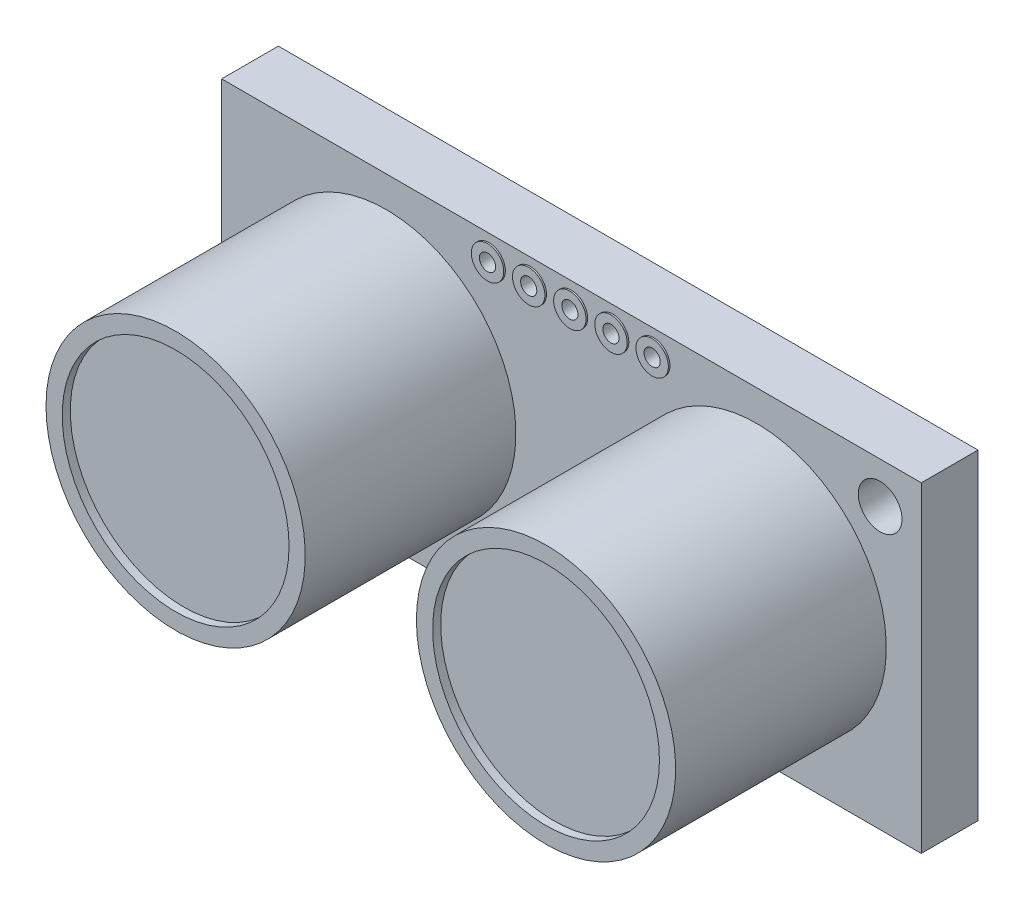
from build123d import *

# Parameters (mm, degrees)
SKETCH1_W                = 43.18
SKETCH1_H                = 19.812
SKETCH1_R                = 1.35
BOSS_EXTRUDE1_DEPTH      = 3.5
SKETCH2_R                = 8
BOSS_EXTRUDE2_DEPTH      = 13
SKETCH3_R                = 7
CUT_EXTRUDE1_DEPTH       = 0.5
SKETCH4_R                = 1
SKETCH4_R_2              = 0.5
EXTRUDE_THIN4_DEPTH      = 0.1
EXTRUDE_THIN4_DEPTH_BACK = 3.6
SKETCH11_R               = 0.5
CUT_EXTRUDE2_DEPTH       = 28.078717399
BOSS_EXTRUDE3_DEPTH      = 0.001


with BuildPart() as part:
    # Sketch1 → Boss-Extrude1 (new body)
    with BuildSketch(Plane.XY):
        Rectangle(SKETCH1_W, SKETCH1_H)
        with Locations((-19.05, -7.366)):
            Circle(SKETCH1_R, mode=Mode.SUBTRACT)
        with Locations((19.05, 7.366)):
            Circle(SKETCH1_R, mode=Mode.SUBTRACT)
    extrude(amount=BOSS_EXTRUDE1_DEPTH)

    # Sketch2 → Boss-Extrude2 (add)
    with BuildSketch(Plane.XY.offset(3.5)):
        with Locations(Location((-11.43, 0, 0), (0, 0, 180))):
            Circle(SKETCH2_R)
        with Locations(Location((11.43, 0, 0), (0, 0, 180))):
            Circle(SKETCH2_R)
    extrude(amount=BOSS_EXTRUDE2_DEPTH)

    # Sketch3 → Cut-Extrude1 (cut)
    with BuildSketch(Plane.XY.offset(16.5)):
        with Locations((-11.43, 0)):
            Circle(SKETCH3_R)
        with Locations((11.43, 0)):
            Circle(SKETCH3_R)
    extrude(amount=-CUT_EXTRUDE1_DEPTH, mode=Mode.SUBTRACT)

    # Sketch4 → Extrude-Thin4 (add, two sides)
    with BuildSketch(Plane.XY.offset(3.5)) as extrude_thin4_sk:
        with Locations((0, 8.406)):
            Circle(SKETCH4_R)
        with Locations((0, 8.406)):
            Circle(SKETCH4_R_2, mode=Mode.SUBTRACT)
        with Locations((2.54, 8.406)):
            Circle(SKETCH4_R)
        with Locations((2.54, 8.406)):
            Circle(SKETCH4_R_2, mode=Mode.SUBTRACT)
        with Locations((5.08, 8.406)):
            Circle(SKETCH4_R)
        with Locations((5.08, 8.406)):
            Circle(SKETCH4_R_2, mode=Mode.SUBTRACT)
        with Locations((-5.08, 8.406)):
            Circle(SKETCH4_R)
        with Locations((-5.08, 8.406)):
            Circle(SKETCH4_R_2, mode=Mode.SUBTRACT)
        with Locations((-2.54, 8.406)):
            Circle(SKETCH4_R)
        with Locations((-2.54, 8.406)):
            Circle(SKETCH4_R_2, mode=Mode.SUBTRACT)
        with Locations((-5.08, -8.406)):
            Circle(SKETCH4_R)
        with Locations((-5.08, -8.406)):
            Circle(SKETCH4_R_2, mode=Mode.SUBTRACT)
        with Locations((-2.54, -8.406)):
            Circle(SKETCH4_R)
        with Locations((-2.54, -8.406)):
            Circle(SKETCH4_R_2, mode=Mode.SUBTRACT)
        with Locations((0, -8.406)):
            Circle(SKETCH4_R)
        with Locations((0, -8.406)):
            Circle(SKETCH4_R_2, mode=Mode.SUBTRACT)
        with Locations((2.54, -8.406)):
            Circle(SKETCH4_R)
        with Locations((2.54, -8.406)):
            Circle(SKETCH4_R_2, mode=Mode.SUBTRACT)
        with Locations((5.08, -8.406)):
            Circle(SKETCH4_R)
        with Locations((5.08, -8.406)):
            Circle(SKETCH4_R_2, mode=Mode.SUBTRACT)
    extrude(amount=EXTRUDE_THIN4_DEPTH)
    extrude(extrude_thin4_sk.sketch, amount=-EXTRUDE_THIN4_DEPTH_BACK)

    # Sketch11 → Cut-Extrude2 (cut, through all)
    with BuildSketch(Plane.XY.offset(3.5)):
        with Locations((-5.08, -8.406)):
            Circle(SKETCH11_R)
        with Locations((-2.54, -8.406)):
            Circle(SKETCH11_R)
        with Locations(Location((0, -8.406, 0), (0, 0, 180))):
            Circle(SKETCH11_R)
        with Locations(Location((2.54, -8.406, 0), (0, 0, 180))):
            Circle(SKETCH11_R)
        with Locations(Location((5.08, -8.406, 0), (0, 0, 180))):
            Circle(SKETCH11_R)
        with Locations(Location((-5.08, 8.406, 0), (0, 0, 180))):
            Circle(SKETCH11_R)
        with Locations(Location((-2.54, 8.406, 0), (0, 0, 180))):
            Circle(SKETCH11_R)
        with Locations((0, 8.406)):
            Circle(SKETCH11_R)
        with Locations((2.54, 8.406)):
            Circle(SKETCH11_R)
        with Locations((5.08, 8.406)):
            Circle(SKETCH11_R)
    extrude(amount=-CUT_EXTRUDE2_DEPTH, mode=Mode.SUBTRACT)

    # Sketch12 → Boss-Extrude3 (add)
    with BuildSketch(Plane(origin=(0, 0, 0), x_dir=(-1, 0, 0), z_dir=(0, 0, -1))):
        with BuildLine():
            add(Edge.make_bspline(
                [(19.46929145, -2.683893026), (19.484417806, -2.684223579), (19.51433311, -2.684877312), (19.55857677, -2.689412347), (19.601609877, -2.696623598), (19.643529262, -2.706555749), (19.684115837, -2.719918963), (19.723610749, -2.736127809), (19.762201128, -2.75474264), (19.799136653, -2.77713075), (19.834715807, -2.80169308), (19.86828259, -2.829333068), (19.900019773, -2.859416979), (19.929842776, -2.892296508), (19.95696226, -2.928352739), (19.982882923, -2.966466663), (20.006501357, -3.007561369), (20.028166536, -3.051214815), (20.047339104, -3.097375117), (20.064173328, -3.145621658), (20.078768602, -3.195935133), (20.090261272, -3.24837133), (20.099075501, -3.302915202), (20.10540034, -3.359565322), (20.109601073, -3.418341945), (20.109976956, -3.458260498), (20.110167222, -3.478466619)],
                knots=[0, 0, 0, 0, 0.949010564, 1.876852617, 2.787529374, 3.685273709, 4.577074086, 5.465471387, 6.362587764, 7.262213343, 8.172580635, 9.073145362, 9.987411958, 10.914456489, 11.85451744, 12.815917507, 13.804911429, 14.825868585, 15.871774033, 16.938849417, 18.030625794, 19.156736427, 20.304747212, 21.4957645, 22.732396811, 24, 24, 24, 24], degree=3))
            add(Edge.make_bspline(
                [(20.110167222, -3.478466619), (20.109713592, -3.502551257), (20.108822914, -3.54984022), (20.103860332, -3.619166231), (20.094377913, -3.685161229), (20.082197449, -3.748129578), (20.065811319, -3.807833441), (20.045507132, -3.864154145), (20.022642346, -3.91766615), (20.003613894, -3.950828686), (19.994191581, -3.967249769)],
                knots=[0, 0, 0, 0, 1.136969792, 2.232382444, 3.278022597, 4.282276305, 5.258039159, 6.196692155, 7.1070566, 8, 8, 8, 8], degree=3))
            add(Edge.make_bspline(
                [(19.994191581, -3.967249769), (19.980125855, -3.988503916), (19.952188373, -4.030719109), (19.900998849, -4.087338382), (19.843562074, -4.138033515), (19.780391, -4.18158225), (19.714579966, -4.217072851), (19.648412339, -4.243220973), (19.582822371, -4.259318087), (19.539200268, -4.261525811), (19.517848725, -4.262606417)],
                knots=[0, 0, 0, 0, 1.048346287, 2.082235551, 3.132143771, 4.197203545, 5.234784445, 6.204564675, 7.121195205, 8, 8, 8, 8], degree=3))
            add(Edge.make_bspline(
                [(19.517848725, -4.262606417), (19.505880841, -4.261996217), (19.482506815, -4.260804457), (19.448934686, -4.251239838), (19.418256579, -4.235582628), (19.390595856, -4.214519543), (19.367774744, -4.188124339), (19.351003002, -4.157808329), (19.340409896, -4.124045436), (19.339393406, -4.100293963), (19.338869017, -4.088041007)],
                knots=[0, 0, 0, 0, 1.029346977, 2.010378973, 2.978887221, 3.98112847, 4.985683985, 5.960201932, 6.947705008, 8, 8, 8, 8], degree=3))
            add(Edge.make_bspline(
                [(19.338869017, -4.088041007), (19.339245694, -4.078080516), (19.339975706, -4.058776797), (19.348168728, -4.031204492), (19.36058334, -4.005800586), (19.37898544, -3.982970809), (19.401999508, -3.962194269), (19.429956992, -3.943235584), (19.462379414, -3.925486113), (19.486424996, -3.91601565), (19.498987635, -3.911067797)],
                knots=[0, 0, 0, 0, 0.932019786, 1.806281372, 2.676477655, 3.570524242, 4.53911087, 5.576821434, 6.734007876, 8, 8, 8, 8], degree=3))
            add(Edge.make_bspline(
                [(19.498987635, -3.911067797), (19.514154901, -3.904497014), (19.543429775, -3.891814514), (19.585067298, -3.871507385), (19.622251922, -3.849696316), (19.656489949, -3.82744116), (19.687800087, -3.802502501), (19.714997365, -3.772135305), (19.740183391, -3.737971347), (19.761936387, -3.698509866), (19.780332925, -3.653726361), (19.792758911, -3.602341133), (19.800986198, -3.544947653), (19.801631627, -3.504449709), (19.80196898, -3.483282216)],
                knots=[0, 0, 0, 0, 1.049630502, 2.025928848, 2.939419198, 3.785195675, 4.618337008, 5.47201057, 6.365697361, 7.308725407, 8.32613671, 9.430404736, 10.656922266, 12, 12, 12, 12], degree=3))
            add(Edge.make_bspline(
                [(19.80196898, -3.483282216), (19.801786665, -3.468289639), (19.801429478, -3.438916536), (19.797209523, -3.39604058), (19.790984576, -3.355224522), (19.781715623, -3.316744761), (19.770034495, -3.280393465), (19.756022784, -3.246070232), (19.739234454, -3.213860117), (19.719531242, -3.184397308), (19.698330902, -3.157558433), (19.676051651, -3.13356403), (19.651734729, -3.113808265), (19.626201925, -3.097691901), (19.599724219, -3.084476637), (19.571616619, -3.075919648), (19.542461561, -3.069773451), (19.522430697, -3.06935428), (19.512230528, -3.069140828)],
                knots=[0, 0, 0, 0, 1.280312405, 2.508357684, 3.676903495, 4.804965861, 5.885491899, 6.935930188, 7.96843881, 8.982636488, 9.958848435, 10.888398438, 11.773624114, 12.626391924, 13.464564268, 14.292153698, 15.130326042, 16, 16, 16, 16], degree=3))
            add(Edge.make_bspline(
                [(19.512230528, -3.069140828), (19.496494601, -3.069862799), (19.466161185, -3.071254509), (19.423077099, -3.083358943), (19.384333744, -3.102661617), (19.351407073, -3.130916015), (19.322475421, -3.164394049), (19.297717898, -3.203046341), (19.27585837, -3.245712555), (19.257854232, -3.293840184), (19.241563213, -3.348197534), (19.224705921, -3.410023046), (19.207664422, -3.480218562), (19.196344494, -3.529818585), (19.190388093, -3.555917479)],
                knots=[0, 0, 0, 0, 0.888922646, 1.713534847, 2.512522705, 3.3189352, 4.1507089, 5.009465297, 5.910012526, 6.858957344, 7.912524916, 9.120887575, 10.485048098, 12, 12, 12, 12], degree=3))
            add(Edge.make_bspline(
                [(19.190388093, -3.555917479), (19.181929691, -3.590087259), (19.165660619, -3.655810153), (19.138396278, -3.749704133), (19.107487465, -3.834351038), (19.075996763, -3.911613713), (19.039365433, -3.980627007), (18.996986053, -4.042080143), (18.948115752, -4.095761163), (18.902393794, -4.13442943), (18.86273622, -4.160699668), (18.831410889, -4.178047101), (18.798259358, -4.192636269), (18.763245036, -4.204110897), (18.726634467, -4.213350814), (18.688309172, -4.220246185), (18.648186982, -4.224299229), (18.620819207, -4.224686994), (18.606898192, -4.224884237)],
                knots=[0, 0, 0, 0, 1.736572963, 3.340162069, 4.820136415, 6.180570834, 7.453029487, 8.666721429, 9.853271306, 11.024342417, 11.610026699, 12.197789198, 12.78876586, 13.39394109, 14.013340947, 14.650211638, 15.313410593, 16, 16, 16, 16], degree=3))
            add(Edge.make_bspline(
                [(18.606898192, -4.224884237), (18.593504819, -4.224740931), (18.567042485, -4.224457791), (18.527951434, -4.219539845), (18.489840843, -4.213216925), (18.453112282, -4.202724962), (18.417329584, -4.190475928), (18.382581113, -4.175232627), (18.349418394, -4.156536443), (18.317126027, -4.135826985), (18.286692517, -4.111986582), (18.25762662, -4.08581059), (18.230312173, -4.057111963), (18.205669793, -4.025320842), (18.181514952, -3.992245277), (18.160416695, -3.955702998), (18.14091815, -3.91689848), (18.11625726, -3.861474515), (18.091695675, -3.786346212), (18.070365196, -3.689863343), (18.058072069, -3.585795903), (18.056383732, -3.513947159), (18.055512274, -3.47686142)],
                knots=[0, 0, 0, 0, 0.769461614, 1.520285473, 2.262551752, 2.988378485, 3.713226575, 4.436358852, 5.166208618, 5.900059362, 6.640050888, 7.38609301, 8.147789305, 8.914131076, 9.697346069, 10.500657756, 11.336485078, 12.193936862, 13.986438256, 15.869279717, 17.867870641, 20, 20, 20, 20], degree=3))
            add(Edge.make_bspline(
                [(18.055512274, -3.47686142), (18.05600825, -3.447276945), (18.056966469, -3.390120075), (18.065519679, -3.307472284), (18.079250927, -3.231021329), (18.098946205, -3.160799164), (18.123752788, -3.096740742), (18.151543955, -3.038011171), (18.183353447, -2.98499297), (18.218799743, -2.938098441), (18.256208591, -2.896738524), (18.29544728, -2.86187447), (18.334774717, -2.831879), (18.375544801, -2.808851006), (18.416194468, -2.790441669), (18.45663055, -2.777736893), (18.496605537, -2.769471846), (18.523121397, -2.768598858), (18.536269428, -2.768165983)],
                knots=[0, 0, 0, 0, 1.50180492, 2.901470176, 4.213680385, 5.441471803, 6.598163128, 7.697894763, 8.73692932, 9.731292389, 10.678417777, 11.563424905, 12.393422888, 13.184490135, 13.9355001, 14.655109254, 15.333128709, 16, 16, 16, 16], degree=3))
            add(Edge.make_bspline(
                [(18.536269428, -2.768165983), (18.547968876, -2.768793298), (18.571072832, -2.770032115), (18.604767094, -2.779696382), (18.636323295, -2.79565456), (18.665371842, -2.817096846), (18.690072435, -2.843185233), (18.708902898, -2.872979724), (18.719626181, -2.906578955), (18.72097737, -2.929949853), (18.721669933, -2.941928794)],
                knots=[0, 0, 0, 0, 0.996524447, 1.967926831, 2.962621832, 3.998325838, 5.031199617, 6.009342139, 6.979672482, 8, 8, 8, 8], degree=3))
            add(Edge.make_bspline(
                [(18.721669933, -2.941928794), (18.721237923, -2.952509599), (18.720422718, -2.97247568), (18.71565128, -3.000753797), (18.705808035, -3.024736317), (18.692326163, -3.045597334), (18.674096087, -3.06379414), (18.652013526, -3.082466258), (18.625325748, -3.101924205), (18.605379739, -3.114352949), (18.594859198, -3.120908502)],
                knots=[0, 0, 0, 0, 1.091037725, 2.058798536, 2.936702634, 3.743333543, 4.601209271, 5.578930148, 6.723004324, 8, 8, 8, 8], degree=3))
            add(Edge.make_bspline(
                [(18.594859198, -3.120908502), (18.575539247, -3.130312653), (18.538259559, -3.14845886), (18.487226134, -3.180663145), (18.443363111, -3.216252044), (18.411121732, -3.248091479), (18.388932809, -3.276172478), (18.375392396, -3.300675856), (18.36395225, -3.327916675), (18.354092471, -3.357915788), (18.347112663, -3.391039717), (18.341977684, -3.42710389), (18.338748427, -3.466102827), (18.338272979, -3.493040834), (18.338027329, -3.506958904)],
                knots=[0, 0, 0, 0, 1.547925219, 2.986869477, 4.337480217, 5.612327564, 6.244828973, 6.909713596, 7.622436063, 8.372459485, 9.181850378, 10.058552105, 10.996911345, 12, 12, 12, 12], degree=3))
            add(Edge.make_bspline(
                [(18.338027329, -3.506958904), (18.338865045, -3.532558407), (18.340463722, -3.581411873), (18.352743768, -3.651016511), (18.374037305, -3.712842943), (18.398984211, -3.758442548), (18.422788372, -3.789499691), (18.44081972, -3.810017039), (18.460169787, -3.826920103), (18.480431517, -3.840723538), (18.501450251, -3.851609225), (18.523287707, -3.860004514), (18.546272099, -3.86424575), (18.561805072, -3.864961487), (18.569577311, -3.865319621)],
                knots=[0, 0, 0, 0, 1.953936482, 3.728844638, 5.372901677, 6.927342473, 7.670868145, 8.357884895, 9.009286022, 9.626820382, 10.225224998, 10.813344112, 11.406232554, 12, 12, 12, 12], degree=3))
            add(Edge.make_bspline(
                [(18.569577311, -3.865319621), (18.579113211, -3.864980933), (18.597877953, -3.864314463), (18.624868169, -3.857681525), (18.649829947, -3.847135242), (18.67264924, -3.832338988), (18.693462973, -3.81368373), (18.712613766, -3.79174254), (18.73098022, -3.767342768), (18.751816257, -3.730051612), (18.774805884, -3.681539116), (18.791979424, -3.629173216), (18.805454941, -3.582429304), (18.816688397, -3.537433055), (18.831039039, -3.483002716), (18.840542262, -3.443308216), (18.845671569, -3.421883348)],
                knots=[0, 0, 0, 0, 0.710597064, 1.398312741, 2.060329599, 2.724976052, 3.418105476, 4.139422309, 4.896209246, 5.692466705, 7.322744487, 8.895039973, 9.798770174, 10.953818098, 12.355841563, 14, 14, 14, 14], degree=3))
            add(Edge.make_bspline(
                [(18.845671569, -3.421883348), (18.852243438, -3.39456596), (18.865099634, -3.341126413), (18.885959774, -3.263074468), (18.907992459, -3.189099277), (18.93074843, -3.118931762), (18.955043623, -3.053188778), (18.983131163, -2.992870483), (19.012545732, -2.937168657), (19.045060109, -2.886506913), (19.081514481, -2.841201333), (19.121641686, -2.800461623), (19.167070347, -2.766064391), (19.216582316, -2.736142614), (19.271527657, -2.71228591), (19.332434707, -2.695591819), (19.3989918, -2.685475813), (19.445309679, -2.684432972), (19.46929145, -2.683893026)],
                knots=[0, 0, 0, 0, 1.267425996, 2.479397737, 3.644026965, 4.748891262, 5.806868875, 6.803181051, 7.748078724, 8.646880768, 9.513885508, 10.367259778, 11.219353025, 12.077259478, 12.971817986, 13.911770136, 14.918787934, 16, 16, 16, 16], degree=3))
        make_face()
        with BuildLine():
            Line((19.236938869, -1.800230878), (19.236938869, -1.939080607))
            Line((19.236938869, -1.939080607), (19.867782146, -1.939080607))
            add(Edge.make_bspline(
                [(19.867782146, -1.939080607), (19.887227731, -1.939569463), (19.923611489, -1.940484139), (19.974280577, -1.950401281), (20.017014821, -1.967090735), (20.051586482, -1.990674356), (20.077777649, -2.01990028), (20.096740238, -2.053243428), (20.108349006, -2.090822708), (20.10955054, -2.117308302), (20.110167222, -2.130901909)],
                knots=[0, 0, 0, 0, 1.331902197, 2.492062242, 3.520752585, 4.456973203, 5.333663409, 6.188000262, 7.069999586, 8, 8, 8, 8], degree=3))
            add(Edge.make_bspline(
                [(20.110167222, -2.130901909), (20.109373291, -2.145409776), (20.107847372, -2.173293636), (20.09683532, -2.212967924), (20.076205729, -2.24664497), (20.048918398, -2.275511003), (20.013410064, -2.297766017), (19.970726045, -2.313122177), (19.921183627, -2.322818647), (19.88575683, -2.3238054), (19.866979546, -2.32432841)],
                knots=[0, 0, 0, 0, 0.98758274, 1.898116353, 2.767902367, 3.650180778, 4.579683533, 5.591031871, 6.723173417, 8, 8, 8, 8], degree=3))
            Line((19.866979546, -2.32432841), (18.351270222, -2.32432841))
            add(Edge.make_bspline(
                [(18.351270222, -2.32432841), (18.331280944, -2.323740288), (18.293773724, -2.322636755), (18.24188352, -2.311937018), (18.198309786, -2.294538775), (18.163257167, -2.268807182), (18.137095477, -2.234173002), (18.11923, -2.191152639), (18.108558909, -2.139709432), (18.107464294, -2.102600256), (18.106878648, -2.082745934)],
                knots=[0, 0, 0, 0, 1.204539147, 2.260157444, 3.178834964, 4.014831347, 4.849268471, 5.763683293, 6.803515522, 8, 8, 8, 8], degree=3))
            Line((18.106878648, -2.082745934), (18.106878648, -1.442271461))
            add(Edge.make_bspline(
                [(18.106878648, -1.442271461), (18.107059476, -1.42100132), (18.107407569, -1.380056515), (18.109303723, -1.320900151), (18.112849589, -1.266553391), (18.117921188, -1.216426566), (18.125407338, -1.169982505), (18.136034656, -1.126315058), (18.148886368, -1.084761869), (18.160527911, -1.058662721), (18.166271017, -1.045787265)],
                knots=[0, 0, 0, 0, 1.263018195, 2.431297115, 3.513891869, 4.496307935, 5.422122339, 6.30446181, 7.163542459, 8, 8, 8, 8], degree=3))
            add(Edge.make_bspline(
                [(18.166271017, -1.045787265), (18.173186513, -1.030381203), (18.186937288, -0.999747782), (18.213068639, -0.956540312), (18.243033035, -0.915964655), (18.27740064, -0.878682035), (18.314738259, -0.844403579), (18.35614933, -0.815189152), (18.399953527, -0.789676869), (18.44667819, -0.768825651), (18.495523638, -0.752581195), (18.54592107, -0.740211327), (18.597885926, -0.73347835), (18.632965113, -0.732475909), (18.650639869, -0.731970825)],
                knots=[0, 0, 0, 0, 0.991101386, 1.970706541, 2.959125982, 3.949043219, 4.94477413, 5.930285116, 6.919453739, 7.918248778, 8.929482208, 9.939493973, 10.961807665, 12, 12, 12, 12], degree=3))
            add(Edge.make_bspline(
                [(18.650639869, -0.731970825), (18.668583461, -0.73232809), (18.703639593, -0.733026073), (18.754754471, -0.73928432), (18.803248931, -0.748815301), (18.849139587, -0.762180424), (18.891914834, -0.780678697), (18.932132977, -0.802137642), (18.96957958, -0.827786237), (19.004173954, -0.857528021), (19.035791681, -0.89170093), (19.065916222, -0.928992469), (19.092585043, -0.97108369), (19.11714069, -1.016954235), (19.139142453, -1.067082964), (19.159163306, -1.121022773), (19.176521958, -1.179220962), (19.185676642, -1.219624181), (19.190388093, -1.240417665)],
                knots=[0, 0, 0, 0, 1.05507517, 2.061284822, 3.02416977, 3.960190338, 4.866266322, 5.760478336, 6.637811303, 7.530498893, 8.437803919, 9.372931164, 10.346335214, 11.363650695, 12.430976955, 13.56370004, 14.746160234, 16, 16, 16, 16], degree=3))
            add(Edge.make_bspline(
                [(19.190388093, -1.240417665), (19.200427827, -1.222376106), (19.220899361, -1.185588436), (19.259959389, -1.133796289), (19.304747277, -1.08278582), (19.356254388, -1.033986697), (19.411591028, -0.986799902), (19.469225772, -0.941636778), (19.528332151, -0.898760059), (19.588907267, -0.859624919), (19.648670628, -0.823618677), (19.706099342, -0.791258715), (19.760703138, -0.763640398), (19.811402894, -0.740153767), (19.856655487, -0.721449354), (19.894955835, -0.708122709), (19.925318671, -0.699169475), (19.94332506, -0.697397202), (19.950851203, -0.696656443)],
                knots=[0, 0, 0, 0, 1.035092047, 2.110606056, 3.247378518, 4.439119437, 5.667527541, 6.896357491, 8.113024158, 9.330801598, 10.514364801, 11.614385948, 12.638182879, 13.584379214, 14.418398752, 15.093545921, 15.621128711, 16, 16, 16, 16], degree=3))
            add(Edge.make_bspline(
                [(19.950851203, -0.696656443), (19.964041869, -0.697988111), (19.991453629, -0.700755473), (20.022873295, -0.717654824), (20.046183068, -0.73517527), (20.062660295, -0.75101425), (20.076500599, -0.769624107), (20.088663848, -0.79012526), (20.098335005, -0.812632242), (20.105021051, -0.837084422), (20.109741287, -0.863148392), (20.110023058, -0.881232034), (20.110167222, -0.890484244)],
                knots=[0, 0, 0, 0, 1.421053962, 2.95311776, 3.768369014, 4.575895034, 5.411397774, 6.266672613, 7.147343469, 8.048766422, 9.001682164, 10, 10, 10, 10], degree=3))
            add(Edge.make_bspline(
                [(20.110167222, -0.890484244), (20.109832205, -0.901356962), (20.109185491, -0.922345541), (20.10279153, -0.952381058), (20.093565654, -0.980199809), (20.074127778, -1.012575278), (20.044129385, -1.049196215), (20.006138096, -1.079661725), (19.970415066, -1.103157313), (19.937742869, -1.124120877), (19.899373952, -1.148105272), (19.871683967, -1.164876217), (19.856947051, -1.173801899)],
                knots=[0, 0, 0, 0, 0.812054064, 1.56758039, 2.289145878, 2.992867892, 4.379130512, 5.807652158, 6.615255223, 7.578411575, 8.711203985, 10, 10, 10, 10], degree=3))
            Line((19.856947051, -1.173801899), (19.591687887, -1.335124416))
            add(Edge.make_bspline(
                [(19.591687887, -1.335124416), (19.568712309, -1.348871396), (19.525264039, -1.374867804), (19.465196917, -1.414237897), (19.413821081, -1.45135698), (19.370496318, -1.486425891), (19.334807335, -1.520807514), (19.305094614, -1.55469524), (19.282105713, -1.589560527), (19.264098857, -1.62500043), (19.25142667, -1.663012017), (19.243523551, -1.704868082), (19.237482435, -1.750965884), (19.237125087, -1.783353374), (19.236938869, -1.800230878)],
                knots=[0, 0, 0, 0, 1.549240544, 2.929711722, 4.154429701, 5.215920692, 6.152032193, 7.019334908, 7.817977517, 8.562251951, 9.313736963, 10.127430344, 11.024181782, 12, 12, 12, 12], degree=3))
        make_face()
        with BuildLine():
            Line((18.41507689, -1.573095194), (18.41507689, -1.939080607))
            Line((18.41507689, -1.939080607), (18.954423814, -1.939080607))
            Line((18.954423814, -1.939080607), (18.954423814, -1.583930289))
            add(Edge.make_bspline(
                [(18.954423814, -1.583930289), (18.954079771, -1.561052235), (18.95341716, -1.516990022), (18.949415073, -1.453810733), (18.941134359, -1.396364754), (18.930772368, -1.34454499), (18.916521718, -1.298160403), (18.897635038, -1.257536318), (18.874321584, -1.222486007), (18.846171277, -1.193339399), (18.812927068, -1.170191533), (18.773918643, -1.154204272), (18.729500531, -1.144486988), (18.698046819, -1.143447393), (18.681539953, -1.142901815)],
                knots=[0, 0, 0, 0, 1.392674693, 2.682235545, 3.849820756, 4.922907172, 5.896284646, 6.795937237, 7.640517491, 8.44662346, 9.24840026, 10.087665541, 10.996409465, 12, 12, 12, 12], degree=3))
            add(Edge.make_bspline(
                [(18.681539953, -1.142901815), (18.668249815, -1.143268512), (18.642212955, -1.143986913), (18.604681271, -1.152433954), (18.569452481, -1.16532031), (18.537115649, -1.183502086), (18.507412206, -1.205750853), (18.482699331, -1.233431705), (18.460183411, -1.263853075), (18.44971231, -1.287133705), (18.444371775, -1.299007435)],
                knots=[0, 0, 0, 0, 1.054707271, 2.066288818, 3.042079463, 4.027441999, 5.005836686, 5.976573042, 6.967999406, 8, 8, 8, 8], degree=3))
            add(Edge.make_bspline(
                [(18.444371775, -1.299007435), (18.441988909, -1.305526806), (18.436809149, -1.319698305), (18.430881077, -1.343610178), (18.426457055, -1.371717154), (18.421820998, -1.403777985), (18.418718916, -1.440083634), (18.417027438, -1.480653587), (18.415124285, -1.525457961), (18.415093129, -1.556773176), (18.41507689, -1.573095194)],
                knots=[0, 0, 0, 0, 0.601274756, 1.307022564, 2.130372336, 3.066540635, 4.11402688, 5.286356465, 6.585603249, 8, 8, 8, 8], degree=3))
        make_face(mode=Mode.SUBTRACT)
        with BuildLine():
            Line((18.41507689, 0.831091874), (18.41507689, 0.03852478))
            Line((18.41507689, 0.03852478), (18.90305744, 0.03852478))
            Line((18.90305744, 0.03852478), (18.90305744, 0.701070741))
            add(Edge.make_bspline(
                [(18.90305744, 0.701070741), (18.903613439, 0.715413667), (18.904661621, 0.742453239), (18.911903609, 0.780369065), (18.925277155, 0.812518682), (18.943900572, 0.838849766), (18.967510759, 0.858807873), (18.994304088, 0.873595087), (19.02506835, 0.882258308), (19.04666647, 0.883180155), (19.057959161, 0.883662148)],
                knots=[0, 0, 0, 0, 1.26669481, 2.387998457, 3.388485007, 4.319542635, 5.207485584, 6.095585677, 7.004267047, 8, 8, 8, 8], degree=3))
            add(Edge.make_bspline(
                [(19.057959161, 0.883662148), (19.069130511, 0.88321293), (19.090655946, 0.882347357), (19.121027017, 0.873143115), (19.147808526, 0.858472273), (19.170645521, 0.837865736), (19.189603068, 0.811861023), (19.202068778, 0.779509499), (19.210356549, 0.742155267), (19.210944216, 0.715302712), (19.211255682, 0.701070741)],
                knots=[0, 0, 0, 0, 0.989664805, 1.906928296, 2.789763925, 3.681746705, 4.618201249, 5.619917427, 6.738545855, 8, 8, 8, 8], degree=3))
            Line((19.211255682, 0.701070741), (19.211255682, 0.03852478))
            Line((19.211255682, 0.03852478), (19.864973047, 0.03852478))
            add(Edge.make_bspline(
                [(19.864973047, 0.03852478), (19.884417787, 0.038018097), (19.921062558, 0.037063222), (19.972118122, 0.027229681), (20.0155337, 0.010593866), (20.050380879, -0.013618022), (20.077248594, -0.042893545), (20.096712963, -0.07623171), (20.108341425, -0.113614522), (20.109547944, -0.139837104), (20.110167222, -0.153296522)],
                knots=[0, 0, 0, 0, 1.324444831, 2.495995325, 3.52738831, 4.471056898, 5.361856607, 6.215950617, 7.08429057, 8, 8, 8, 8], degree=3))
            add(Edge.make_bspline(
                [(20.110167222, -0.153296522), (20.109605163, -0.167039311), (20.108513617, -0.193728494), (20.096189432, -0.231456844), (20.077015102, -0.265268078), (20.049944741, -0.29453884), (20.015324498, -0.318815862), (19.972223157, -0.334677303), (19.92222676, -0.345509719), (19.886177446, -0.346301411), (19.866979546, -0.346723022)],
                knots=[0, 0, 0, 0, 0.935929894, 1.817622685, 2.681511336, 3.574268386, 4.520010484, 5.54180128, 6.690897382, 8, 8, 8, 8], degree=3))
            Line((19.866979546, -0.346723022), (18.351270222, -0.346723022))
            add(Edge.make_bspline(
                [(18.351270222, -0.346723022), (18.337613974, -0.346409172), (18.31156212, -0.345810443), (18.274308319, -0.341478689), (18.240859588, -0.334033398), (18.211201187, -0.323269338), (18.185352027, -0.309076693), (18.163231499, -0.291310698), (18.145502574, -0.269437557), (18.130724475, -0.244671574), (18.120020842, -0.216084928), (18.112619549, -0.184100213), (18.107659661, -0.148632924), (18.107146592, -0.123752337), (18.106878648, -0.110758743)],
                knots=[0, 0, 0, 0, 1.24824502, 2.381261253, 3.422463234, 4.374230178, 5.255516348, 6.107294269, 6.949627804, 7.815767679, 8.733215993, 9.726798055, 10.812847089, 12, 12, 12, 12], degree=3))
            Line((18.106878648, -0.110758743), (18.106878648, 0.831091874))
            add(Edge.make_bspline(
                [(18.106878648, 0.831091874), (18.107419374, 0.846105218), (18.108431651, 0.874211211), (18.115756938, 0.913549918), (18.128983591, 0.94682447), (18.147704949, 0.974014748), (18.171111535, 0.994724783), (18.197774958, 1.01008444), (18.228041573, 1.019081164), (18.2492808, 1.020022521), (18.260175169, 1.020505377)],
                knots=[0, 0, 0, 0, 1.305293606, 2.443597845, 3.460957068, 4.396713591, 5.286368424, 6.156339552, 7.054319707, 8, 8, 8, 8], degree=3))
            add(Edge.make_bspline(
                [(18.260175169, 1.020505377), (18.271334872, 1.020028052), (18.292966356, 1.019102824), (18.323677153, 1.010177935), (18.350433405, 0.994714209), (18.373878091, 0.974028619), (18.392484118, 0.946733302), (18.406327536, 0.913658099), (18.413481542, 0.874193565), (18.414521419, 0.846099074), (18.41507689, 0.831091874)],
                knots=[0, 0, 0, 0, 0.964185515, 1.868935361, 2.734709653, 3.620072693, 4.551315024, 5.56819034, 6.701003273, 8, 8, 8, 8], degree=3))
        make_face()
        with BuildLine():
            add(Edge.make_bspline(
                [(19.106516436, 2.632526652), (19.141835751, 2.632229246), (19.209967989, 2.631655539), (19.308249757, 2.626997012), (19.398761863, 2.618602882), (19.482253002, 2.607057531), (19.560542405, 2.591720398), (19.634128598, 2.569881976), (19.704417817, 2.543184103), (19.748384706, 2.520578198), (19.770266296, 2.509327615)],
                knots=[0, 0, 0, 0, 1.24224353, 2.396332709, 3.459542317, 4.438314338, 5.360108057, 6.262326286, 7.135188689, 8, 8, 8, 8], degree=3))
            add(Edge.make_bspline(
                [(19.770266296, 2.509327615), (19.796238869, 2.493356301), (19.84731425, 2.461948518), (19.915518903, 2.4049938), (19.973914595, 2.340776938), (20.014915562, 2.282067001), (20.042671038, 2.232414747), (20.060896355, 2.194117806), (20.076073961, 2.154782925), (20.088693451, 2.114329505), (20.098197263, 2.072848493), (20.104920753, 2.030337976), (20.109716099, 1.986944655), (20.110015719, 1.957553808), (20.110167222, 1.942692305)],
                knots=[0, 0, 0, 0, 1.580397239, 3.107870444, 4.591483573, 6.071993126, 6.811458575, 7.540989501, 8.270454403, 8.997041459, 9.737775931, 10.475970176, 11.229373204, 12, 12, 12, 12], degree=3))
            add(Edge.make_bspline(
                [(20.110167222, 1.942692305), (20.109718196, 1.925559498), (20.108832126, 1.891751038), (20.103695385, 1.841654894), (20.094349905, 1.79312107), (20.081613702, 1.745786103), (20.06442702, 1.700104779), (20.044636251, 1.655282106), (20.020197098, 1.612285153), (19.992671858, 1.570639979), (19.961742497, 1.530994432), (19.928087771, 1.493560555), (19.89131671, 1.458963723), (19.851884325, 1.426791904), (19.809563419, 1.396930283), (19.764310686, 1.369821714), (19.716326927, 1.345111161), (19.682882324, 1.331027441), (19.665928349, 1.323888022)],
                knots=[0, 0, 0, 0, 1.013654932, 2.000262503, 2.974897205, 3.934739091, 4.89611284, 5.859471119, 6.830211065, 7.817833599, 8.810294581, 9.80196658, 10.792754173, 11.793821649, 12.810314228, 13.853919655, 14.912093751, 16, 16, 16, 16], degree=3))
            add(Edge.make_bspline(
                [(19.665928349, 1.323888022), (19.647007278, 1.317362039), (19.608570638, 1.304105029), (19.548417049, 1.288361527), (19.485529948, 1.274586148), (19.419582491, 1.263994583), (19.350935851, 1.255380462), (19.279537018, 1.250156534), (19.205413136, 1.246244083), (19.155079376, 1.245840526), (19.129390524, 1.245634562)],
                knots=[0, 0, 0, 0, 0.881300005, 1.790290336, 2.736775026, 3.716068374, 4.731167005, 5.783179305, 6.86860072, 8, 8, 8, 8], degree=3))
            add(Edge.make_bspline(
                [(19.129390524, 1.245634562), (19.096478877, 1.24581142), (19.032368438, 1.246155933), (18.938700156, 1.250395995), (18.850071591, 1.256551884), (18.766655823, 1.265702143), (18.688568653, 1.277654723), (18.616097279, 1.292412755), (18.549010143, 1.309616833), (18.507144394, 1.324648709), (18.486909553, 1.331914018)],
                knots=[0, 0, 0, 0, 1.212279312, 2.361466649, 3.453316133, 4.484503641, 5.451820176, 6.362159784, 7.208387816, 8, 8, 8, 8], degree=3))
            add(Edge.make_bspline(
                [(18.486909553, 1.331914018), (18.470762432, 1.338797397), (18.439090545, 1.35229885), (18.393905476, 1.375770783), (18.351605985, 1.401428877), (18.312314366, 1.429638291), (18.275545254, 1.459621046), (18.242124048, 1.49238498), (18.211643121, 1.527246128), (18.184075597, 1.564314197), (18.160261953, 1.603782107), (18.138751625, 1.644597846), (18.120956434, 1.68760281), (18.106794002, 1.732538064), (18.094866717, 1.779084947), (18.08704658, 1.827573387), (18.082066536, 1.877843888), (18.081489197, 1.912047461), (18.081195461, 1.929449412)],
                knots=[0, 0, 0, 0, 1.091111206, 2.140167975, 3.162946158, 4.164640209, 5.145466981, 6.110078272, 7.070916974, 8.022458711, 8.978207941, 9.93428284, 10.888873235, 11.867369661, 12.861889973, 13.873753768, 14.918217287, 16, 16, 16, 16], degree=3))
            add(Edge.make_bspline(
                [(18.081195461, 1.929449412), (18.081723841, 1.95221394), (18.08275952, 1.99683471), (18.091218762, 2.062204185), (18.10583724, 2.124195221), (18.125387812, 2.183190919), (18.150790744, 2.238690583), (18.181388382, 2.290787594), (18.217460233, 2.339211537), (18.258478864, 2.38436989), (18.305210684, 2.425912391), (18.356731361, 2.464235634), (18.413602923, 2.49918336), (18.454096894, 2.51914973), (18.474870559, 2.529392605)],
                knots=[0, 0, 0, 0, 1.074291325, 2.105719259, 3.104291516, 4.076669601, 5.034507252, 5.979860306, 6.923186968, 7.879670961, 8.854444549, 9.869744472, 10.907165378, 12, 12, 12, 12], degree=3))
            add(Edge.make_bspline(
                [(18.474870559, 2.529392605), (18.494274321, 2.537752753), (18.534475983, 2.555073718), (18.599412009, 2.575284139), (18.669748181, 2.593668212), (18.745981047, 2.607674679), (18.827921243, 2.618995107), (18.915642296, 2.626780271), (19.009211874, 2.631677728), (19.073469623, 2.632238338), (19.106516436, 2.632526652)],
                knots=[0, 0, 0, 0, 0.786151885, 1.628787956, 2.528718292, 3.491837123, 4.512437559, 5.607691779, 6.769671193, 8, 8, 8, 8], degree=3))
        make_face()
        with BuildLine():
            add(Edge.make_bspline(
                [(19.079629349, 2.272962036), (19.059696796, 2.27292552), (19.020761012, 2.27285419), (18.963770403, 2.271119664), (18.909457568, 2.268706556), (18.857917259, 2.265723448), (18.809109524, 2.261095884), (18.763157111, 2.256178964), (18.719979547, 2.249536306), (18.667478266, 2.240450974), (18.607712381, 2.225851541), (18.543220143, 2.20308724), (18.48859093, 2.173999166), (18.449507112, 2.145591622), (18.424452393, 2.119130012), (18.407853958, 2.098402936), (18.393978671, 2.075662432), (18.383278075, 2.050817014), (18.374487988, 2.024516972), (18.367893165, 1.996476021), (18.364382389, 1.96659381), (18.363938817, 1.946045064), (18.363710516, 1.935468909)],
                knots=[0, 0, 0, 0, 1.347647352, 2.632462932, 3.854663529, 5.023633764, 6.122520203, 7.169251864, 8.147763337, 9.075642165, 10.771294062, 12.302045326, 13.685839966, 14.944833451, 15.546133651, 16.145048405, 16.737578031, 17.340915391, 17.970135936, 18.610758548, 19.284976654, 20, 20, 20, 20], degree=3))
            add(Edge.make_bspline(
                [(18.363710516, 1.935468909), (18.364192231, 1.920571457), (18.365124992, 1.891725042), (18.373978349, 1.85030237), (18.38730497, 1.811959373), (18.407436578, 1.777584114), (18.432609229, 1.746561269), (18.463620675, 1.719445005), (18.500299644, 1.696182912), (18.542466521, 1.675985409), (18.590624731, 1.659655884), (18.644281719, 1.644595282), (18.703994544, 1.632458566), (18.769778441, 1.622552916), (18.841391229, 1.614569266), (18.919168931, 1.609042924), (19.002821843, 1.605950238), (19.060631927, 1.60545483), (19.090464444, 1.605199178)],
                knots=[0, 0, 0, 0, 0.800712426, 1.5504452, 2.270089568, 2.976430944, 3.68255215, 4.411961279, 5.182793406, 6.01355921, 6.922072822, 7.915944648, 9.011614588, 10.198826553, 11.495524534, 12.888644882, 14.39440548, 16, 16, 16, 16], degree=3))
            add(Edge.make_bspline(
                [(19.090464444, 1.605199178), (19.110932047, 1.605235546), (19.150937738, 1.605306631), (19.20953304, 1.607046425), (19.265318486, 1.609439052), (19.318326037, 1.612464562), (19.368476214, 1.617041909), (19.415761158, 1.621990873), (19.460144471, 1.628626051), (19.514234474, 1.637735082), (19.575762032, 1.652193043), (19.64206719, 1.675095787), (19.69827873, 1.704165433), (19.738723218, 1.732537503), (19.764738151, 1.758881379), (19.782047496, 1.779363482), (19.795956602, 1.802112464), (19.807690286, 1.82611383), (19.81660243, 1.851871007), (19.822885677, 1.879181091), (19.827116195, 1.908183521), (19.827470833, 1.928096222), (19.827652166, 1.938278008)],
                knots=[0, 0, 0, 0, 1.360892793, 2.659982061, 3.897473583, 5.073706367, 6.189819789, 7.245725, 8.234419589, 9.173203856, 10.892611866, 12.431469099, 13.823825965, 15.090508813, 15.694289814, 16.281935201, 16.869311273, 17.462050397, 18.055589799, 18.676935243, 19.323488959, 20, 20, 20, 20], degree=3))
            add(Edge.make_bspline(
                [(19.827652166, 1.938278008), (19.827459482, 1.94885691), (19.827084799, 1.969428031), (19.823076503, 1.999320288), (19.815980489, 2.027298693), (19.807168508, 2.053975455), (19.794348351, 2.078281146), (19.779943836, 2.101385361), (19.762022261, 2.122077728), (19.734815917, 2.148329389), (19.693617662, 2.176787199), (19.636475088, 2.205337947), (19.570015243, 2.227952713), (19.508582913, 2.24168281), (19.454797363, 2.250393776), (19.410377564, 2.256473852), (19.362862263, 2.261558762), (19.312170783, 2.26607211), (19.258506704, 2.269258193), (19.201629692, 2.270974914), (19.141709106, 2.272893639), (19.100632508, 2.272938896), (19.079629349, 2.272962036)],
                knots=[0, 0, 0, 0, 0.693691847, 1.348913083, 1.972464501, 2.585744591, 3.186146807, 3.7702996, 4.368002788, 4.976177112, 6.247129624, 7.632347309, 9.155818429, 10.839487285, 11.755496797, 12.729633812, 13.780021632, 14.889824529, 16.067712469, 17.305706588, 18.622362222, 20, 20, 20, 20], degree=3))
        make_face(mode=Mode.SUBTRACT)
        with BuildLine():
            Line((18.41507689, 4.052325325), (18.41507689, 3.408640455))
            Line((18.41507689, 3.408640455), (18.858111863, 3.331590894))
            add(Edge.make_bspline(
                [(18.858111863, 3.331590894), (18.849372161, 3.347416978), (18.83232872, 3.378279694), (18.810301299, 3.425128392), (18.791180191, 3.470806149), (18.776098168, 3.515810941), (18.763708031, 3.559663658), (18.755451, 3.602771566), (18.749823896, 3.64485691), (18.749243379, 3.672678346), (18.748958319, 3.686339912)],
                knots=[0, 0, 0, 0, 1.156031135, 2.254395925, 3.309385178, 4.321273619, 5.288520282, 6.221443175, 7.12664928, 8, 8, 8, 8], degree=3))
            add(Edge.make_bspline(
                [(18.748958319, 3.686339912), (18.749600508, 3.707640722), (18.750874786, 3.749907314), (18.760265351, 3.812058908), (18.775697892, 3.872119109), (18.796795396, 3.929746056), (18.82385133, 3.984318175), (18.855490592, 4.035561129), (18.892390055, 4.082624178), (18.933223116, 4.126200608), (18.979003778, 4.165238096), (19.028649006, 4.200166769), (19.082499766, 4.230364357), (19.139784898, 4.256072517), (19.200278086, 4.276420961), (19.263235659, 4.291389899), (19.32857065, 4.300458239), (19.372950592, 4.301437359), (19.395452288, 4.301933797)],
                knots=[0, 0, 0, 0, 1.026611596, 2.037076288, 3.022413444, 4.011898786, 4.989546235, 5.954025754, 6.909843404, 7.867790456, 8.828122028, 9.804918424, 10.789537881, 11.79981737, 12.827582723, 13.861459599, 14.915708723, 16, 16, 16, 16], degree=3))
            add(Edge.make_bspline(
                [(19.395452288, 4.301933797), (19.427760845, 4.301000554), (19.491452581, 4.299160798), (19.584540928, 4.282526958), (19.673344131, 4.256153624), (19.743115518, 4.224727502), (19.796031193, 4.195027439), (19.833505069, 4.169956984), (19.868923881, 4.142628055), (19.902292054, 4.11283599), (19.93379586, 4.080629702), (19.962913853, 4.045791009), (19.989948876, 4.008625047), (20.014790425, 3.969371525), (20.037215678, 3.928101777), (20.057080893, 3.885039332), (20.073469972, 3.840048223), (20.086652966, 3.793324917), (20.097070771, 3.745070865), (20.104800343, 3.695108082), (20.109155907, 3.643345), (20.109827056, 3.608228002), (20.110167222, 3.590429262)],
                knots=[0, 0, 0, 0, 1.711147685, 3.37328478, 4.994949039, 6.610339793, 7.416750561, 8.209202439, 8.997679871, 9.78606167, 10.578228054, 11.383422398, 12.190331681, 13.012514466, 13.843726651, 14.67810767, 15.523709018, 16.378768627, 17.249296324, 18.138703239, 19.056618197, 20, 20, 20, 20], degree=3))
            add(Edge.make_bspline(
                [(20.110167222, 3.590429262), (20.110029573, 3.570620959), (20.10976134, 3.532021183), (20.104957625, 3.475528244), (20.098416024, 3.421904449), (20.088923802, 3.371014887), (20.075862869, 3.323271736), (20.060882851, 3.278195185), (20.042627602, 3.236101435), (20.015367049, 3.184968357), (19.97737006, 3.127927944), (19.928051276, 3.068075475), (19.875002096, 3.019232253), (19.818791666, 2.982463432), (19.763375376, 2.955233192), (19.710956897, 2.935049363), (19.661819588, 2.922646891), (19.630004461, 2.92075278), (19.614963275, 2.919857305)],
                knots=[0, 0, 0, 0, 1.032093293, 2.011205585, 2.952964999, 3.847252965, 4.706415705, 5.531020485, 6.32109392, 7.094596524, 8.548774814, 9.885141963, 11.128927262, 12.291106832, 13.373074573, 14.341704631, 15.216010439, 16, 16, 16, 16], degree=3))
            add(Edge.make_bspline(
                [(19.614963275, 2.919857305), (19.606210548, 2.920433457), (19.588608352, 2.921592128), (19.562731976, 2.930058215), (19.537928092, 2.944245064), (19.514260253, 2.962997428), (19.494033772, 2.986363654), (19.47858252, 3.013046312), (19.469540552, 3.042885546), (19.468578208, 3.063730026), (19.468087551, 3.074357726)],
                knots=[0, 0, 0, 0, 0.891772366, 1.793401163, 2.746006762, 3.79412415, 4.857924086, 5.878153834, 6.918162393, 8, 8, 8, 8], degree=3))
            add(Edge.make_bspline(
                [(19.468087551, 3.074357726), (19.468458986, 3.08361867), (19.469183352, 3.101679177), (19.475268649, 3.127847084), (19.486010538, 3.15189885), (19.50068826, 3.174213056), (19.519323785, 3.194825984), (19.54212509, 3.213335038), (19.569003822, 3.229972694), (19.588895456, 3.238986017), (19.599312583, 3.243706239)],
                knots=[0, 0, 0, 0, 0.971980174, 1.895536086, 2.801396063, 3.724951974, 4.689900168, 5.708100931, 6.799746478, 8, 8, 8, 8], degree=3))
            add(Edge.make_bspline(
                [(19.599312583, 3.243706239), (19.618605276, 3.252947921), (19.656231428, 3.270971788), (19.706342123, 3.306101341), (19.750693166, 3.344688241), (19.787040057, 3.38871904), (19.816822057, 3.436007575), (19.837697662, 3.486927191), (19.851313901, 3.540358549), (19.85265739, 3.57710356), (19.853335353, 3.595646159)],
                knots=[0, 0, 0, 0, 1.114388395, 2.173369472, 3.181905356, 4.172949301, 5.141395086, 6.086316069, 7.034299513, 8, 8, 8, 8], degree=3))
            add(Edge.make_bspline(
                [(19.853335353, 3.595646159), (19.852823796, 3.61256197), (19.851822654, 3.64566697), (19.840895931, 3.693386761), (19.823949337, 3.737974842), (19.800131474, 3.778859097), (19.770506171, 3.815975639), (19.736015029, 3.849272129), (19.695423165, 3.876987169), (19.650592086, 3.900560261), (19.601617798, 3.919494935), (19.549026832, 3.93253509), (19.493361462, 3.940778383), (19.455142016, 3.941830655), (19.435582267, 3.942369181)],
                knots=[0, 0, 0, 0, 0.999542791, 1.956150026, 2.880941895, 3.813831331, 4.743625034, 5.684375802, 6.639737325, 7.641941603, 8.677003637, 9.738847702, 10.842799317, 12, 12, 12, 12], degree=3))
            add(Edge.make_bspline(
                [(19.435582267, 3.942369181), (19.414676468, 3.941924173), (19.374401046, 3.941066855), (19.316299573, 3.931840157), (19.262818184, 3.917800449), (19.214337515, 3.897570273), (19.171207667, 3.872680684), (19.133582011, 3.843744443), (19.101582822, 3.810769135), (19.075938787, 3.773769963), (19.056398044, 3.733667052), (19.041564366, 3.691616294), (19.033067487, 3.647086334), (19.032009752, 3.616682262), (19.031473374, 3.601264356)],
                knots=[0, 0, 0, 0, 1.264307668, 2.435712816, 3.551282472, 4.603813104, 5.605052054, 6.557298982, 7.467737889, 8.37511164, 9.269460386, 10.16050474, 11.067191922, 12, 12, 12, 12], degree=3))
            add(Edge.make_bspline(
                [(19.031473374, 3.601264356), (19.031628773, 3.583181318), (19.031916326, 3.549720191), (19.03772147, 3.503682886), (19.045706175, 3.465480839), (19.059271863, 3.43370358), (19.078135731, 3.404385076), (19.100499511, 3.371318288), (19.127967926, 3.332434303), (19.159541042, 3.290663784), (19.189767927, 3.247997146), (19.212540417, 3.207222667), (19.227341726, 3.170181789), (19.229520531, 3.146292656), (19.230518072, 3.135355295)],
                knots=[0, 0, 0, 0, 1.253320121, 2.319162568, 3.215033915, 3.951008832, 4.700606019, 5.629743289, 6.721449385, 8.002092677, 9.263357855, 10.343167053, 11.241438274, 12, 12, 12, 12], degree=3))
            add(Edge.make_bspline(
                [(19.230518072, 3.135355295), (19.229874574, 3.124456411), (19.228613145, 3.103091687), (19.219280336, 3.07193618), (19.203906581, 3.042885246), (19.18262433, 3.016799516), (19.158027101, 2.994698815), (19.130976942, 2.977985205), (19.101867706, 2.967830534), (19.081712863, 2.966615988), (19.071603354, 2.966006781)],
                knots=[0, 0, 0, 0, 1.021493999, 2.002401241, 3.024126496, 4.086435777, 5.144287797, 6.112833732, 7.053412325, 8, 8, 8, 8], degree=3))
            add(Edge.make_bspline(
                [(19.071603354, 2.966006781), (19.068790919, 2.966247304), (19.059906835, 2.967007082), (19.041630388, 2.970270162), (19.013415348, 2.974955147), (18.991209461, 2.97870752), (18.978501801, 2.980854874)],
                knots=[0, 0, 0, 0, 0.359093097, 1.134324626, 2.360073298, 4, 4, 4, 4], degree=3))
            Line((18.978501801, 2.980854874), (18.321975337, 3.094422716))
            add(Edge.make_bspline(
                [(18.321975337, 3.094422716), (18.304351772, 3.097885412), (18.271150508, 3.104408831), (18.225763768, 3.119886248), (18.188025222, 3.139696931), (18.156850682, 3.163659733), (18.133064708, 3.195027974), (18.118076223, 3.234349173), (18.108274262, 3.280947768), (18.107366378, 3.31467561), (18.106878648, 3.332794793)],
                knots=[0, 0, 0, 0, 1.194129083, 2.249635226, 3.177331393, 4.019641834, 4.845571199, 5.759547176, 6.796389752, 8, 8, 8, 8], degree=3))
            Line((18.106878648, 3.332794793), (18.106878648, 4.044299329))
            add(Edge.make_bspline(
                [(18.106878648, 4.044299329), (18.107284527, 4.060245639), (18.108046585, 4.090185616), (18.115071789, 4.132191378), (18.127314844, 4.167840112), (18.144393195, 4.19754394), (18.166860371, 4.220796847), (18.194920954, 4.23666268), (18.227408985, 4.246622876), (18.25073308, 4.247630409), (18.262984268, 4.248159625)],
                knots=[0, 0, 0, 0, 1.306773136, 2.453530613, 3.476791313, 4.381515022, 5.242365076, 6.092600397, 6.998121453, 8, 8, 8, 8], degree=3))
            add(Edge.make_bspline(
                [(18.262984268, 4.248159625), (18.27388415, 4.247548867), (18.295033553, 4.246363794), (18.325140412, 4.236965643), (18.351451876, 4.220704031), (18.37428354, 4.198622855), (18.392891039, 4.170511211), (18.406268197, 4.13624861), (18.413449514, 4.096095313), (18.41451386, 4.067468615), (18.41507689, 4.052325325)],
                knots=[0, 0, 0, 0, 0.934297721, 1.812848832, 2.673138209, 3.566118365, 4.518019535, 5.543292166, 6.700421607, 8, 8, 8, 8], degree=3))
        make_face()
    extrude(amount=BOSS_EXTRUDE3_DEPTH)


solid = part.part
